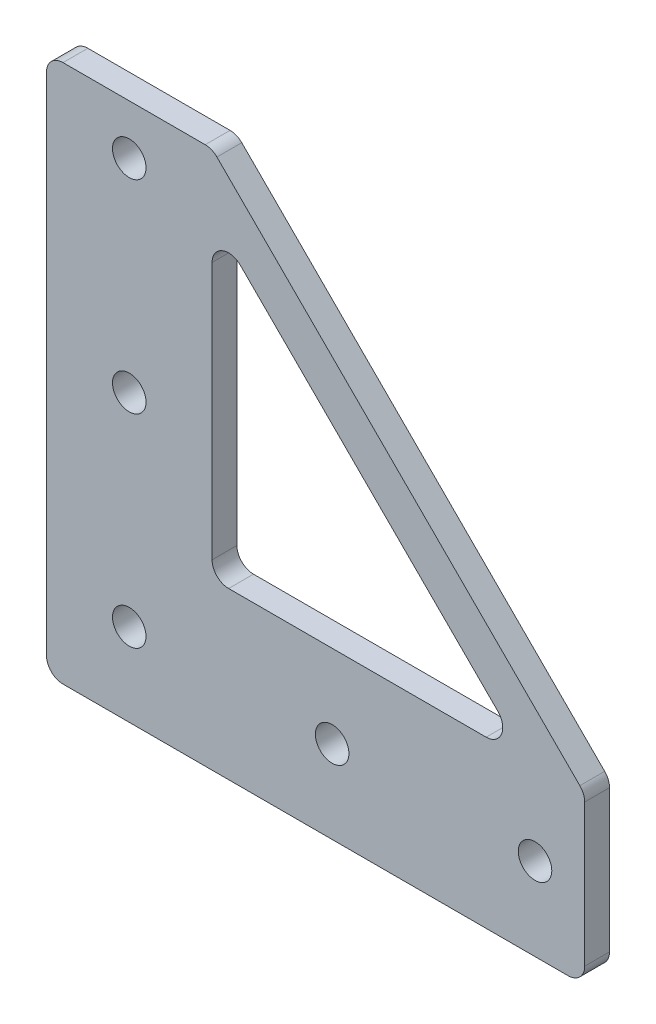
from build123d import *

# Parameters (mm, degrees)
EXTRUDE_1_DEPTH     = 3
SKETCH_2_R          = 2.025
CUT_EXTRUDE_1_DEPTH = 3
EXTRUDE_2_DEPTH     = 3
FILLET_1_R          = 2


with BuildPart() as part:
    # 草图1 → 凸台-拉伸1 (new body)
    with BuildSketch(Plane.XY):
        Polygon((0, 0), (0, 65), (20, 65), (20, 20), (65, 20), (65, 0), align=None)
    extrude(amount=EXTRUDE_1_DEPTH)

    # 草图2 → 切除-拉伸1 (cut)
    with BuildSketch(Plane.XY.offset(3)):
        with Locations((10, 59)):
            Circle(SKETCH_2_R)
        with Locations((10, 34.5)):
            Circle(SKETCH_2_R)
        with Locations((10, 10)):
            Circle(SKETCH_2_R)
        with Locations((34.5, 10)):
            Circle(SKETCH_2_R)
        with Locations((59, 10)):
            Circle(SKETCH_2_R)
    extrude(amount=-CUT_EXTRUDE_1_DEPTH, mode=Mode.SUBTRACT)

    # 草图3 → 凸台-拉伸2 (add)
    with BuildSketch(Plane.XY.offset(3)):
        Polygon((20, 65), (65, 20), (57.928932188, 20), (20, 57.928932188), align=None)
    extrude(amount=-EXTRUDE_2_DEPTH)

    # 圆角1
    fillet_1_edges = [part.edges().sort_by_distance(p)[0] for p in [
        (0, 0, 1.5),
        (0, 65, 1.5),
        (20, 65, 1.5),
        (20, 20, 1.5),
        (65, 20, 1.5),
        (65, 0, 1.5),
        (57.928932188, 20, 1.5),
        (20, 57.928932188, 1.5),
    ]]
    fillet(fillet_1_edges, radius=FILLET_1_R)


solid = part.part
